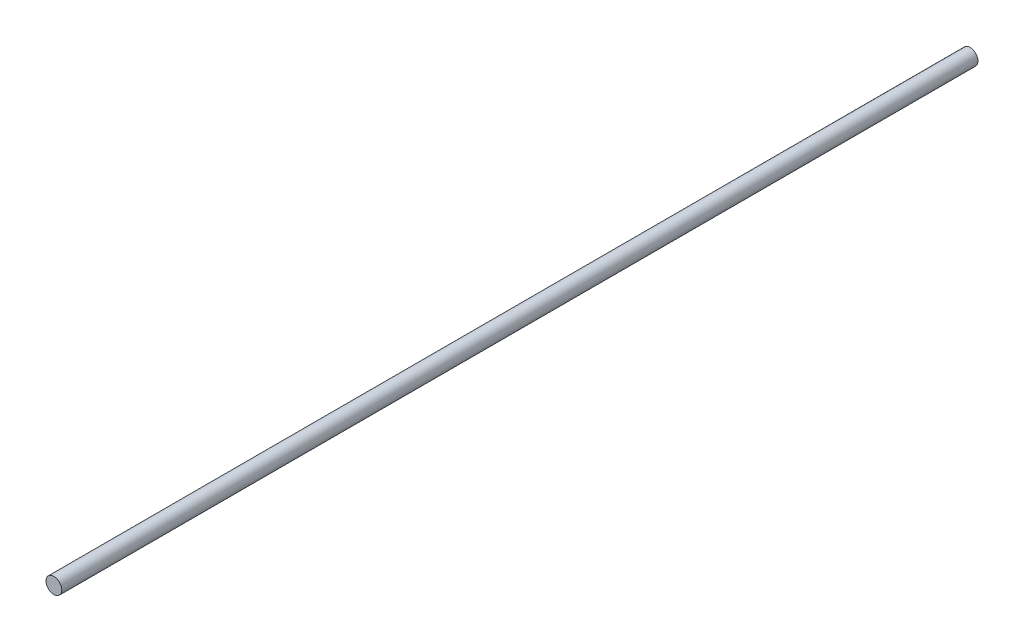
from build123d import *

# Parameters (mm, degrees)
ESQUISSE1_R        = 5
BOSS_EXTRU_1_DEPTH = 580


with BuildPart() as part:
    # Esquisse1 → Boss.-Extru.1 (new body)
    with BuildSketch(Plane.XY):
        Circle(ESQUISSE1_R)
    extrude(amount=BOSS_EXTRU_1_DEPTH)


solid = part.part
